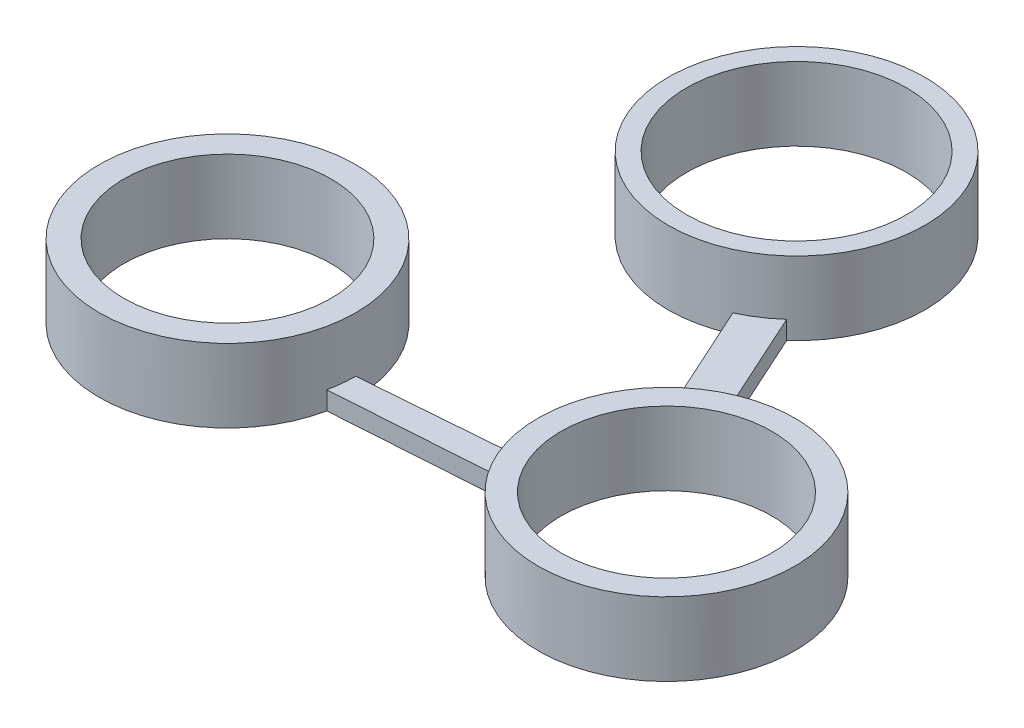
from build123d import *

# Parameters (mm, degrees)
SKETCH_1_R        = 7
SKETCH_1_R_2      = 5.65
EXTRUDE_1_DEPTH   = 4
SKETCH_1_R_3      = 5.75
EXTRUDE_1_2_DEPTH = 4
SKETCH_1_R_4      = 6
EXTRUDE_1_3_DEPTH = 4
EXTRUDE_2_DEPTH   = 1


with BuildPart() as part:
    # 草图1 → 凸台-拉伸1 (new body)
    with BuildSketch(Plane(origin=(0, 0, 0), x_dir=(1, 0, 0), z_dir=(0, 1, 0))):
        with Locations((-73.735173333, 44.289748166)):
            Circle(SKETCH_1_R)
        with Locations((-73.735173333, 44.289748166)):
            Circle(SKETCH_1_R_2, mode=Mode.SUBTRACT)
    extrude(amount=EXTRUDE_1_DEPTH)



with BuildPart() as body_2:
    # 草图1 → Extrude 1 2 (new body)
    with BuildSketch(Plane(origin=(0, 0, 0), x_dir=(1, 0, 0), z_dir=(0, 1, 0))):
        with Locations((-49.788051119, 44.289748166)):
            Circle(SKETCH_1_R)
        with Locations((-49.788051119, 44.289748166)):
            Circle(SKETCH_1_R_3, mode=Mode.SUBTRACT)
    extrude(amount=EXTRUDE_1_2_DEPTH)


with BuildPart() as body_3:
    # 草图1 → Extrude 1 3 (new body)
    with BuildSketch(Plane(origin=(0, 0, 0), x_dir=(1, 0, 0), z_dir=(0, 1, 0))):
        with Locations((-62.341002405, 63.939282004)):
            Circle(SKETCH_1_R)
        with Locations((-62.341002405, 63.939282004)):
            Circle(SKETCH_1_R_4, mode=Mode.SUBTRACT)
    extrude(amount=EXTRUDE_1_3_DEPTH)


with BuildPart() as part_1:
    add(part.part)

    add(body_2.part)  # 凸台-拉伸2 merges body 2

    add(body_3.part)  # 凸台-拉伸2 merges body 3
    # 草图2 → 凸台-拉伸2 (add)
    with BuildSketch(Plane(origin=(0, 0, 0), x_dir=(1, 0, 0), z_dir=(0, 1, 0))):
        Polygon((-66.735173333, 44.289748166), (-56.743768428, 45.075875842), (-56.371981746, 43.565889762), (-67.1134612, 42.842031358), align=None)
        Polygon((-59.44276594, 57.567451388), (-55.341606688, 48.550971059), (-53.588038725, 49.751237508), (-57.6700519, 58.725624806), align=None)
    extrude(amount=EXTRUDE_2_DEPTH)


solid = part_1.part
